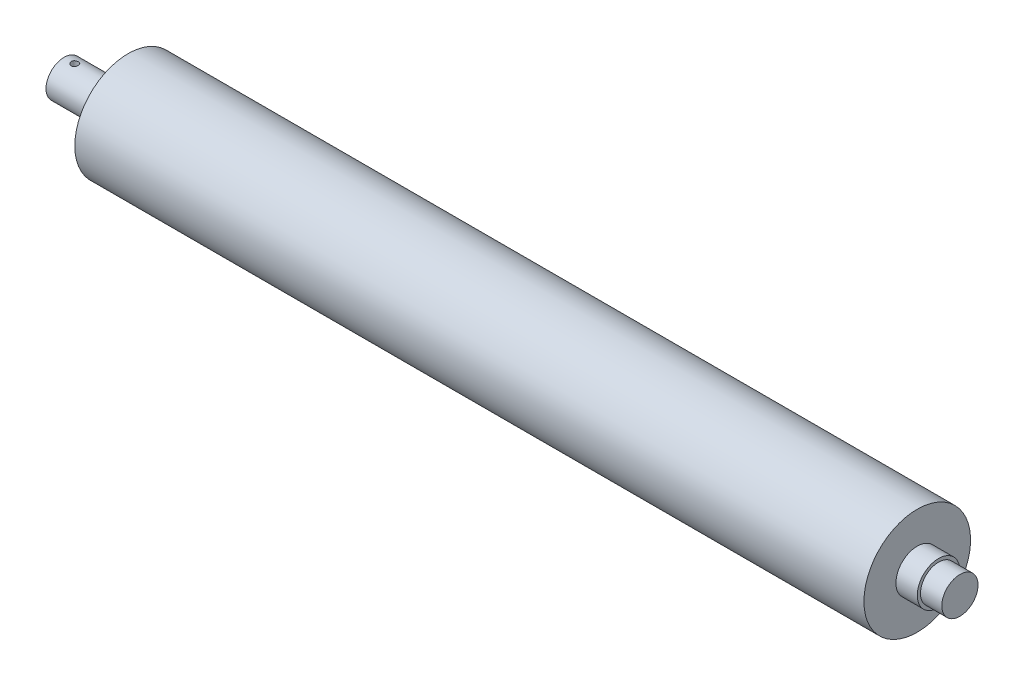
from build123d import *

# Parameters (mm, degrees)
HOLE_WIZARD_M4_1_D     = 3.3
HOLE_WIZARD_M4_1_DEPTH = 20
HOLE_WIZARD_M4_1_TIP   = 0.991420021
MM_CLEARANCE_1_D       = 12.1
MM_CLEARANCE_1_DEPTH   = 12
MM_CLEARANCE_1_TIP     = 3.635206745


with BuildPart() as part:
    # 草图2 → 旋转1 (revolve)
    with BuildSketch(Plane.XY):
        Polygon((354.507854502, 10), (344.507854502, 10), (344.507854502, 25), (-25.492145498, 25), (-25.492145498, 10), (-35.492145498, 10), (-35.492145498, 8.5), (-45.492145498, 8.5), (-55.492145498, 8.5), (-55.492145498, 0), (-39.793794406, 0), (364.507854502, 0), (364.507854502, 8.5), (354.507854502, 8.5), align=None)
    revolve(axis=Axis((-62.705882353, 0, 0), (1, 0, 0)))

    # M4 螺纹孔1
    with Locations(Plane(origin=(0, 8.5, 0), x_dir=(1, 0, 0), z_dir=(0, 1, 0))):
        with Locations((-50.492145498, 0)):
            Hole(HOLE_WIZARD_M4_1_D / 2, depth=HOLE_WIZARD_M4_1_DEPTH)
            with Locations((0, 0, -(HOLE_WIZARD_M4_1_DEPTH + HOLE_WIZARD_M4_1_TIP / 2))):  # 118° drill point
                Cone(0, HOLE_WIZARD_M4_1_D / 2, HOLE_WIZARD_M4_1_TIP, mode=Mode.SUBTRACT)

    # 大小mm Clearance 暗销孔1
    with Locations(Plane.ZY.offset(55.492145498)):
        with Locations((0, 0)):
            Hole(MM_CLEARANCE_1_D / 2, depth=MM_CLEARANCE_1_DEPTH)
            with Locations((0, 0, -(MM_CLEARANCE_1_DEPTH + MM_CLEARANCE_1_TIP / 2))):  # 118° drill point
                Cone(0, MM_CLEARANCE_1_D / 2, MM_CLEARANCE_1_TIP, mode=Mode.SUBTRACT)


solid = part.part
